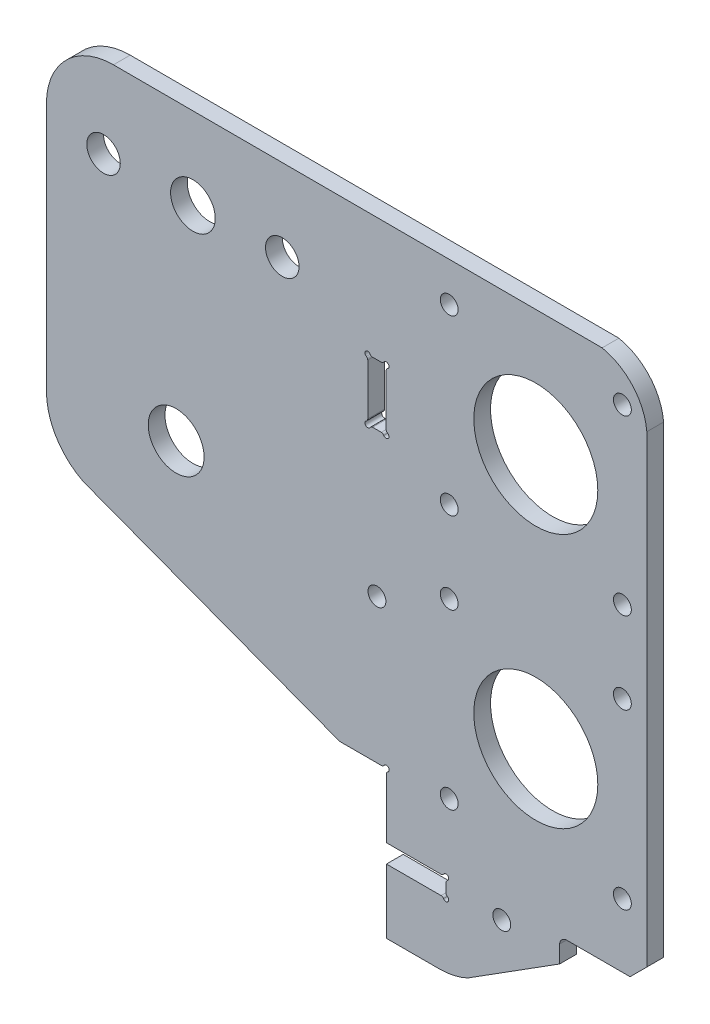
from build123d import *

# Parameters (mm, degrees)
SKETCH2_R           = 1.6
SKETCH2_R_2         = 11.1
SKETCH2_R_3         = 3
SKETCH2_R_4         = 5
SKETCH2_R_5         = 4
BOSS_EXTRUDE1_DEPTH = 3


with BuildPart() as part:
    # Sketch2 → Boss-Extrude1 (new body)
    with BuildSketch(Plane.XY):
        with BuildLine():
            Line((614.435102185, 461.225170893), (623.90331335, 461.224719403))
            ThreePointArc((623.90331335, 461.224719403), (626.504195172, 461.509935711), (628.981434701, 462.352087069))
            Line((628.981434701, 462.352087069), (645.437814692, 472.74939936))
            Line((645.437814692, 472.74939936), (645.437805999, 475.842263452))
            ThreePointArc((645.437805999, 475.842263452), (645.827256367, 476.692258934), (646.675721819, 477.085031495))
            Line((646.675721819, 477.085031495), (651.053167865, 477.08497795))
            Line((651.053167865, 477.08497795), (658.053167865, 477.084892327))
            Line((658.053167865, 477.084892327), (661.05320456, 480.08485563))
            Line((661.05320456, 480.08485563), (661.053938478, 563.084855626))
            ThreePointArc((661.053938478, 563.084855626), (658.545785906, 568.910909563), (653.054048566, 572.084953481))
            Line((653.054048566, 572.084953481), (565.568648825, 572.225226264))
            ThreePointArc((565.568648825, 572.225226264), (557.08332923, 568.710610374), (553.568511969, 560.225374189))
            Line((553.568511969, 560.225374189), (553.568247664, 515.617572657))
            ThreePointArc((553.568247664, 515.617572657), (555.351154886, 509.323701089), (560.170211258, 504.900096998))
            Line((560.170211258, 504.900096998), (606.080895677, 487.576006806))
            Line((606.080895677, 487.576006806), (613.572105954, 487.575380074))
            ThreePointArc((613.572105954, 487.575380074), (613.822124483, 487.64230545), (614.005183481, 487.825274503))
            ThreePointArc((614.005183481, 487.825274503), (614.791773675, 487.928636269), (614.688030581, 487.142096277))
            ThreePointArc((614.688030581, 487.142096277), (614.504973528, 486.959127354), (614.437926006, 486.709143073))
            Line((614.437926006, 486.709143073), (614.43788575, 476.049724775))
            Line((614.43788575, 476.049724775), (624.220719005, 476.049608672))
            ThreePointArc((624.220719005, 476.049608672), (624.470734348, 476.116535454), (624.653790913, 476.299503103))
            ThreePointArc((624.653790913, 476.299503103), (625.440382085, 476.402865597), (625.336639048, 475.616324524))
            ThreePointArc((625.336639048, 475.616324524), (625.153582047, 475.433355654), (625.086534543, 475.183371443))
            Line((625.086534543, 475.183371443), (625.086160971, 473.615504488))
            ThreePointArc((625.086160971, 473.615504488), (625.15308783, 473.365488935), (625.336055679, 473.182432256))
            ThreePointArc((625.336055679, 473.182432256), (625.439417924, 472.395841553), (624.652877353, 472.499584586))
            ThreePointArc((624.652877353, 472.499584586), (624.46990843, 472.682641639), (624.219924149, 472.749689162))
            Line((624.219924149, 472.749689162), (614.437846894, 472.749804566))
            Line((614.437846894, 472.749804566), (614.435102185, 461.225170893))
        make_face()
        with Locations((635.087868744, 474.399923822)):
            Circle(SKETCH2_R, mode=Mode.SUBTRACT)
        with Locations((656.676324975, 488.487527015)):
            Circle(SKETCH2_R, mode=Mode.SUBTRACT)
        with Locations((625.676324975, 488.487527015)):
            Circle(SKETCH2_R, mode=Mode.SUBTRACT)
        with Locations((625.676324975, 534.094134141)):
            Circle(SKETCH2_R, mode=Mode.SUBTRACT)
        with Locations((641.176324975, 549.594134141)):
            Circle(SKETCH2_R_2, mode=Mode.SUBTRACT)
        with Locations((612.74313993, 513.399851045)):
            Circle(SKETCH2_R, mode=Mode.SUBTRACT)
        with Locations((656.676324975, 519.487527015)):
            Circle(SKETCH2_R, mode=Mode.SUBTRACT)
        with Locations((641.176324975, 503.987527015)):
            Circle(SKETCH2_R_2, mode=Mode.SUBTRACT)
        with Locations((625.676324975, 519.487527015)):
            Circle(SKETCH2_R, mode=Mode.SUBTRACT)
        with Locations((595.79313993, 557.52985104)):
            Circle(SKETCH2_R_3, mode=Mode.SUBTRACT)
        with Locations((656.676324975, 534.094134141)):
            Circle(SKETCH2_R, mode=Mode.SUBTRACT)
        with Locations((576.79313993, 519.52985104)):
            Circle(SKETCH2_R_4, mode=Mode.SUBTRACT)
        with Locations((579.79313993, 557.52985104)):
            Circle(SKETCH2_R_5, mode=Mode.SUBTRACT)
        with Locations((563.79313993, 557.52985104)):
            Circle(SKETCH2_R_3, mode=Mode.SUBTRACT)
        with Locations((625.676324975, 565.094134141)):
            Circle(SKETCH2_R, mode=Mode.SUBTRACT)
        with Locations((656.676324975, 565.094134141)):
            Circle(SKETCH2_R, mode=Mode.SUBTRACT)
        with BuildLine():
            Line((611.093697619, 549.224479725), (611.093697619, 540.09139539))
            ThreePointArc((611.093697619, 540.09139539), (611.02668037, 539.841343608), (610.843593883, 539.658322999))
            ThreePointArc((610.843593883, 539.658322999), (610.739850849, 538.871781922), (611.526442023, 538.975144428))
            ThreePointArc((611.526442023, 538.975144428), (611.709498586, 539.158112071), (611.959513926, 539.225038851))
            Line((611.959513926, 539.225038851), (613.527379805, 539.225038851))
            ThreePointArc((613.527379805, 539.225038851), (613.777380678, 539.158051129), (613.960393664, 538.975037363))
            ThreePointArc((613.960393664, 538.975037363), (614.746958334, 538.871481536), (614.643409294, 539.6580471))
            ThreePointArc((614.643409294, 539.6580471), (614.460398347, 539.841059611), (614.393411762, 540.091058378))
            Line((614.393411762, 540.091058378), (614.393411762, 549.224816737))
            ThreePointArc((614.393411762, 549.224816737), (614.460398347, 549.474815504), (614.643409294, 549.657828015))
            ThreePointArc((614.643409294, 549.657828015), (614.746958334, 550.444393579), (613.960393664, 550.340837752))
            ThreePointArc((613.960393664, 550.340837752), (613.777380678, 550.157823986), (613.527379805, 550.090836264))
            Line((613.527379805, 550.090836264), (611.959513926, 550.090836264))
            ThreePointArc((611.959513926, 550.090836264), (611.709498586, 550.157763044), (611.526442023, 550.340730687))
            ThreePointArc((611.526442023, 550.340730687), (610.739850849, 550.444093193), (610.843593883, 549.657552116))
            ThreePointArc((610.843593883, 549.657552116), (611.02668037, 549.474531507), (611.093697619, 549.224479725))
        make_face(mode=Mode.SUBTRACT)
    extrude(amount=BOSS_EXTRUDE1_DEPTH)


solid = part.part
